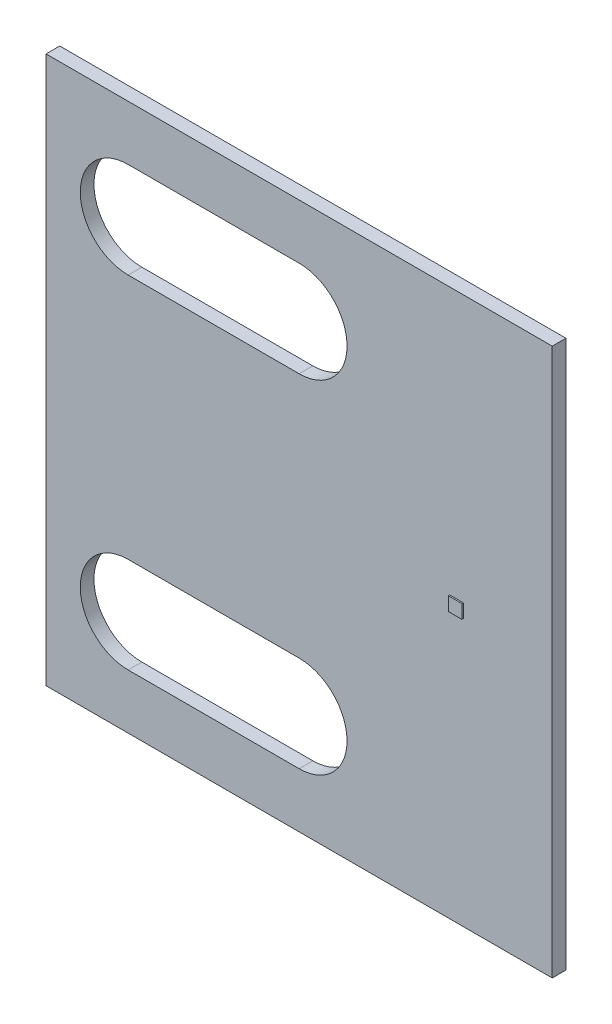
from build123d import *

# Parameters (mm, degrees)
SKETCH1_W           = 37
SKETCH1_H           = 40
BOSS_EXTRUDE1_DEPTH = 1
SKETCH2_W           = 1
SKETCH2_H           = 1
BOSS_EXTRUDE2_DEPTH = 0.1
CUT_EXTRUDE1_DEPTH  = 2


with BuildPart() as part:
    # Sketch1 → Boss-Extrude1 (new body)
    with BuildSketch(Plane.XY):
        with Locations((-11.5, 0)):
            Rectangle(SKETCH1_W, SKETCH1_H)
    extrude(amount=BOSS_EXTRUDE1_DEPTH)

    # Sketch2 → Boss-Extrude2 (add)
    with BuildSketch(Plane.XY.offset(1)):
        Rectangle(SKETCH2_W, SKETCH2_H)
    extrude(amount=BOSS_EXTRUDE2_DEPTH)

    # Sketch3 → Cut-Extrude1 (cut, through all)
    with BuildSketch(Plane.XY.offset(1)):
        with BuildLine():
            Line((-24, 16), (-11.5, 16))
            ThreePointArc((-11.5, 16), (-8, 12.5), (-11.5, 9))
            Line((-11.5, 9), (-24, 9))
            ThreePointArc((-24, 9), (-27.5, 12.5), (-24, 16))
        make_face()
    cut_extrude1 = extrude(amount=-CUT_EXTRUDE1_DEPTH, mode=Mode.SUBTRACT)

    # Mirror1: Cut-Extrude1 across plane
    add(cut_extrude1.mirror(Plane.ZX), mode=Mode.SUBTRACT)


solid = part.part
